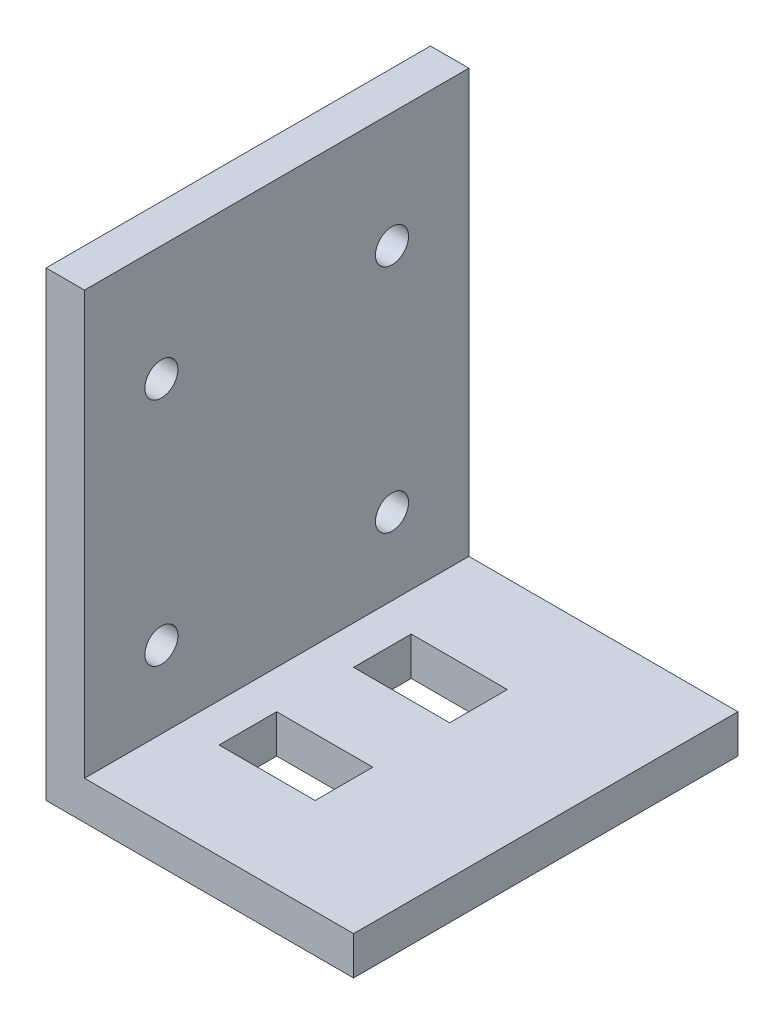
from build123d import *

# Parameters (mm, degrees)
BOSS_EXTRUDE1_DEPTH = 31.75
SKETCH2_R           = 1.366728635
CUT_EXTRUDE1_DEPTH  = 4.175
SKETCH4_W           = 7.9375
SKETCH4_H           = 4.7625
CUT_EXTRUDE2_DEPTH  = 4.175


with BuildPart() as part:
    # Sketch1 → Boss-Extrude1 (new body)
    with BuildSketch(Plane.XY):
        Polygon((0, 0), (25.4, 0), (25.4, 3.175), (3.175, 3.175), (3.175, 38.1), (0, 38.1), align=None)
    extrude(amount=BOSS_EXTRUDE1_DEPTH)

    # Sketch2 → Cut-Extrude1 (cut, through all)
    with BuildSketch(Plane(origin=(3.175, 0, 0), x_dir=(0, 0, -1), z_dir=(1, 0, 0))):
        with Locations((-25.4, 28.575)):
            Circle(SKETCH2_R)
        with Locations((-6.35, 28.575)):
            Circle(SKETCH2_R)
        with Locations((-25.4, 9.525)):
            Circle(SKETCH2_R)
        with Locations((-6.35, 9.525)):
            Circle(SKETCH2_R)
    extrude(amount=-CUT_EXTRUDE1_DEPTH, mode=Mode.SUBTRACT)

    # Sketch4 → Cut-Extrude2 (cut, through all)
    with BuildSketch(Plane(origin=(0, 3.175, 0), x_dir=(1, 0, 0), z_dir=(0, 1, 0))):
        with Locations((10.31875, -21.43125)):
            Rectangle(SKETCH4_W, SKETCH4_H)
        with Locations((10.31875, -10.31875)):
            Rectangle(SKETCH4_W, SKETCH4_H)
    extrude(amount=-CUT_EXTRUDE2_DEPTH, mode=Mode.SUBTRACT)


solid = part.part
